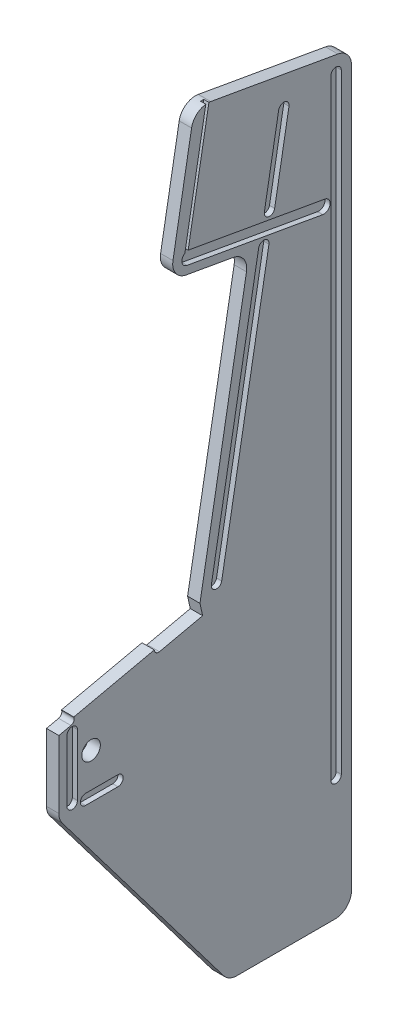
from build123d import *

# Parameters (mm, degrees)
BOSS_EXTRUDE1_DEPTH     = 9.525
FILLET1_R               = 25.4
BOSS_EXTRUDE2_DEPTH     = 19.05
FILLET2_R               = 6.35
CUT_EXTRUDE1_DEPTH      = 7.9375
SKETCH9_R               = 14.2875
CUT_EXTRUDE3_DEPTH      = 10.525
CUT_EXTRUDE3_DEPTH_BACK = 10.525


with BuildPart() as part:
    # Sketch1 → Boss-Extrude1 (new body, symmetric)
    with BuildSketch(Plane(origin=(0, 0, 0), x_dir=(0, 0, -1), z_dir=(1, 0, 0))):
        Polygon((0, 0), (0, -112.563749307), (261.582885953, -457.593888215), (450.85, -457.593888215), (450.85, 690.679166755), (208.861297127, 733.352902663), (171.366736958, 520.733599781), (293.482501466, 499.198975136), (217.390599948, 67.706860465), (221.513774593, 49.108421529), align=None)
    extrude(amount=BOSS_EXTRUDE1_DEPTH, both=True)

    # Fillet1
    fillet1_edges = [part.edges().sort_by_distance(p)[0] for p in [
        (0, 499.198975136, -293.482501466),
        (0, 520.733599781, -171.366736958),
        (0, 733.352902663, -208.861297127),
        (0, 690.679166755, -450.85),
        (0, -457.593888215, -450.85),
        (0, -457.593888215, -261.582885953),
        (0, -112.563749307, 0),
    ]]
    fillet(fillet1_edges, radius=FILLET1_R)

    # Sketch5 → Boss-Extrude2 (add)
    with BuildSketch(Plane(origin=(9.525, 0, 0), x_dir=(0, 0, -1), z_dir=(1, 0, 0))):
        Polygon((24.797918581, 5.497566194), (23.079929145, 13.246915751), (147.069522049, 40.734746721), (148.787511485, 32.985397164), align=None)
    extrude(amount=-BOSS_EXTRUDE2_DEPTH)

    # Fillet2
    fillet2_edges = [part.edges().sort_by_distance(p)[0] for p in [
        (0, 32.985397164, -148.787511485),
        (0, 5.497566194, -24.797918581),
    ]]
    fillet(fillet2_edges, radius=FILLET2_R)

    # Sketch6 → Cut-Extrude1 (cut)
    with BuildSketch(Plane(origin=(9.525, 0, 0), x_dir=(0, 0, -1), z_dir=(1, 0, 0))):
        with BuildLine():
            Line((28.6385, -6.365075015), (28.6385, -100.980075015))
            ThreePointArc((28.6385, -100.980075015), (20.574, -109.044575015), (12.5095, -100.980075015))
            Line((12.5095, -100.980075015), (12.5095, -6.365075015))
            ThreePointArc((12.5095, -6.365075015), (20.574, 1.699424985), (28.6385, -6.365075015))
        make_face()
        with BuildLine():
            Line((418.973, -269.390231885), (418.973, 670.409768115))
            ThreePointArc((418.973, 670.409768115), (427.0375, 678.474268115), (435.102, 670.409768115))
            Line((435.102, 670.409768115), (435.102, -269.390231885))
            ThreePointArc((435.102, -269.390231885), (427.0375, -277.454731885), (418.973, -269.390231885))
        make_face()
        with BuildLine():
            Line((354.524032203, 662.256458615), (332.470713639, 537.185873983))
            ThreePointArc((332.470713639, 537.185873983), (323.128345786, 530.644277587), (316.586749391, 539.98664544))
            Line((316.586749391, 539.98664544), (338.640067954, 665.057230073))
            ThreePointArc((338.640067954, 665.057230073), (347.982435807, 671.598826468), (354.524032203, 662.256458615))
        make_face()
        with BuildLine():
            Line((406.559861559, 491.68872453), (197.491872287, 528.553051841))
            ThreePointArc((197.491872287, 528.553051841), (189.629312583, 536.333399232), (194.145410605, 546.430849865))
            Line((194.145410605, 546.430849865), (228.335527156, 740.311741223))
            ThreePointArc((228.335527156, 740.311741223), (231.057354489, 742.217510482), (232.963123748, 739.495683149))
            Line((232.963123748, 739.495683149), (199.190848291, 547.984231028))
            Line((199.190848291, 547.984231028), (409.934019299, 510.824523979))
            ThreePointArc((409.934019299, 510.824523979), (417.814840153, 499.569545384), (406.559861559, 491.68872453))
        make_face()
        with BuildLine():
            Line((250.866088981, 80.873965121), (323.642040242, 493.606894408))
            ThreePointArc((323.642040242, 493.606894408), (317.100443846, 502.949262261), (307.758075993, 496.407665866))
            Line((307.758075993, 496.407665866), (234.982124733, 83.674736578))
            ThreePointArc((234.982124733, 83.674736578), (241.523721128, 74.332368726), (250.866088981, 80.873965121))
        make_face()
        with BuildLine():
            Line((41.2115, -97.692152626), (91.0115, -97.692152626))
            ThreePointArc((91.0115, -97.692152626), (99.076, -105.756652626), (91.0115, -113.821152626))
            Line((91.0115, -113.821152626), (41.2115, -113.821152626))
            ThreePointArc((41.2115, -113.821152626), (33.147, -105.756652626), (41.2115, -97.692152626))
        make_face()
    extrude(amount=-CUT_EXTRUDE1_DEPTH, mode=Mode.SUBTRACT)

    # Sketch9 → Cut-Extrude3 (cut, two sides)
    with BuildSketch(Plane(origin=(0, 0, 0), x_dir=(0, 0, -1), z_dir=(1, 0, 0))) as cut_extrude3_sk:
        with Locations((49.5935, -44.45)):
            Circle(SKETCH9_R)
    extrude(amount=CUT_EXTRUDE3_DEPTH, mode=Mode.SUBTRACT)
    extrude(cut_extrude3_sk.sketch, amount=-CUT_EXTRUDE3_DEPTH_BACK, mode=Mode.SUBTRACT)


solid = part.part
